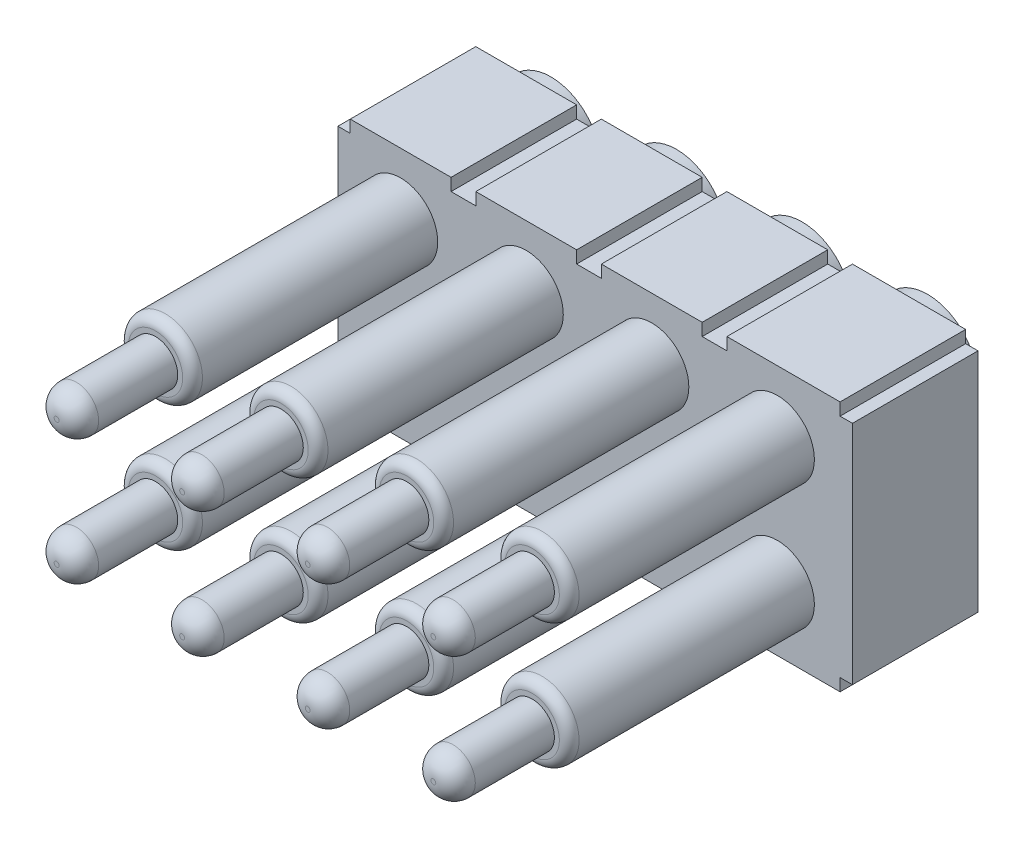
from build123d import *

# Parameters (mm, degrees)
EXTRUDE_1_DEPTH = 2.54
SKETCH_2_R      = 1
EXTRUDE_2_DEPTH = 0.5
SKETCH_3_R      = 0.75
EXTRUDE_3_DEPTH = 8
SKETCH_4_R      = 0.45
EXTRUDE_4_DEPTH = 2
FILLET_1_R      = 0.4
FILLET_2_R      = 0.2


with BuildPart() as part:
    # 草图1 → 凸台-拉伸1 (new body)
    with BuildSketch(Plane.XY):
        Polygon((5.08, 2.29), (5.08, 2.54), (2.79, 2.54), (2.79, 2.29), (2.29, 2.29), (2.29, 2.54), (0.25, 2.54), (0.25, 2.29), (-0.25, 2.29), (-0.25, 2.54), (-2.29, 2.54), (-2.29, 2.29), (-2.79, 2.29), (-2.79, 2.54), (-4.83, 2.54), (-4.83, 2.29), (-5.08, 2.29), (-5.08, -2.29), (-4.83, -2.29), (-4.83, -2.54), (-2.79, -2.54), (-2.79, -2.29), (-2.29, -2.29), (-2.29, -2.54), (-0.25, -2.54), (-0.25, -2.29), (0.25, -2.29), (0.25, -2.54), (2.29, -2.54), (2.29, -2.29), (2.79, -2.29), (2.79, -2.54), (5.08, -2.54), (5.08, -2.29), (5.33, -2.29), (5.33, 0), (5.33, 2.29), align=None)
    extrude(amount=EXTRUDE_1_DEPTH)

    # 草图2 → 凸台-拉伸2 (add)
    with BuildSketch(Plane(origin=(0, 0, 0), x_dir=(-1, 0, 0), z_dir=(0, 0, -1))):
        with Locations((-1.27, 1.27)):
            Circle(SKETCH_2_R)
        with Locations((1.27, 1.27)):
            Circle(SKETCH_2_R)
        with Locations((3.81, 1.27)):
            Circle(SKETCH_2_R)
        with Locations((1.27, -1.27)):
            Circle(SKETCH_2_R)
        with Locations((3.81, -1.27)):
            Circle(SKETCH_2_R)
        with Locations((-1.27, -1.27)):
            Circle(SKETCH_2_R)
        with Locations((-3.81, 1.27)):
            Circle(SKETCH_2_R)
        with Locations((-3.81, -1.27)):
            Circle(SKETCH_2_R)
    extrude(amount=EXTRUDE_2_DEPTH)

    # 草图3 → 凸台-拉伸3 (add)
    with BuildSketch(Plane(origin=(0, 0, -0.5), x_dir=(-1, 0, 0), z_dir=(0, 0, -1))):
        with Locations((-3.81, 1.27)):
            Circle(SKETCH_3_R)
        with Locations((-1.27, 1.27)):
            Circle(SKETCH_3_R)
        with Locations((1.27, 1.27)):
            Circle(SKETCH_3_R)
        with Locations((3.81, 1.27)):
            Circle(SKETCH_3_R)
        with Locations((-1.27, -1.27)):
            Circle(SKETCH_3_R)
        with Locations((1.27, -1.27)):
            Circle(SKETCH_3_R)
        with Locations((3.81, -1.27)):
            Circle(SKETCH_3_R)
        with Locations((-3.81, -1.27)):
            Circle(SKETCH_3_R)
    extrude(amount=-EXTRUDE_3_DEPTH)

    # 草图4 → 凸台-拉伸4 (add)
    with BuildSketch(Plane.XY.offset(7.5)):
        with Locations((-3.81, 1.27)):
            Circle(SKETCH_4_R)
        with Locations((-1.27, 1.27)):
            Circle(SKETCH_4_R)
        with Locations((1.27, 1.27)):
            Circle(SKETCH_4_R)
        with Locations((3.81, 1.27)):
            Circle(SKETCH_4_R)
        with Locations((-1.27, -1.27)):
            Circle(SKETCH_4_R)
        with Locations((1.27, -1.27)):
            Circle(SKETCH_4_R)
        with Locations((3.81, -1.27)):
            Circle(SKETCH_4_R)
        with Locations((-3.81, -1.27)):
            Circle(SKETCH_4_R)
    extrude(amount=EXTRUDE_4_DEPTH)

    # 圆角1
    fillet_1_edges = [part.edges().sort_by_distance(p)[0] for p in [
        (-4.26, 1.27, 9.5),
        (-1.72, 1.27, 9.5),
        (0.82, 1.27, 9.5),
        (3.36, 1.27, 9.5),
        (-1.72, -1.27, 9.5),
        (0.82, -1.27, 9.5),
        (3.36, -1.27, 9.5),
        (-4.26, -1.27, 9.5),
    ]]
    fillet(fillet_1_edges, radius=FILLET_1_R)

    # 圆角2
    fillet_2_edges = [part.edges().sort_by_distance(p)[0] for p in [
        (4.56, 1.27, 7.5),
        (2.02, 1.27, 7.5),
        (-0.52, 1.27, 7.5),
        (-3.06, 1.27, 7.5),
        (2.02, -1.27, 7.5),
        (-0.52, -1.27, 7.5),
        (-3.06, -1.27, 7.5),
        (4.56, -1.27, 7.5),
    ]]
    fillet(fillet_2_edges, radius=FILLET_2_R)


solid = part.part
